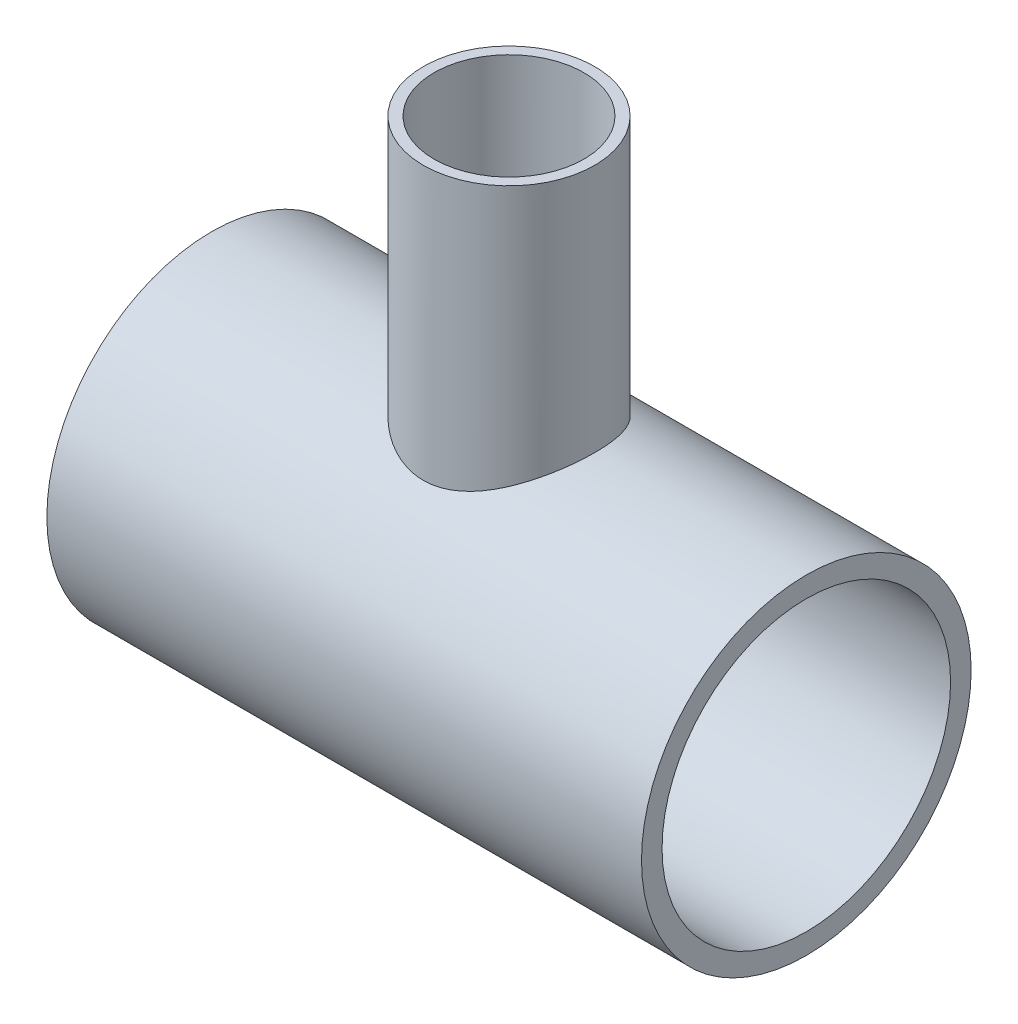
from build123d import *

# Parameters (mm, degrees)
REVOLVE_OF_12_NOM_W           = 584.2
REVOLVE_OF_12_NOM_H           = 20.193
F_6_NOM_OD_EXTRUDE_REACH      = 661.193
F_6_NOM_OD_EXTRUDE_END_RADIUS = 161.925
SKETCH2_R                     = 84.1375
F_6_NOM_ID_EXTRUDE_CUT_REACH  = 661.193
F_6_NOM_ID_EXTRUDE_R          = 73.6473


with BuildPart() as part:
    # Revolve of 12 NOM → Revolve12 NOM (revolve)
    with BuildSketch(Plane.XY):
        with Locations((0, 151.8285)):
            Rectangle(REVOLVE_OF_12_NOM_W, REVOLVE_OF_12_NOM_H)
    revolve(axis=Axis((0, 0, 0), (1, 0, 0)))

    # 6 NOM OD Extrude: up to this cylinder (the profile starts outside it)
    f_6_nom_od_extrude_end = Plane(origin=(0, 0, 0), z_dir=(-1, 0, 0)) * Cylinder(F_6_NOM_OD_EXTRUDE_END_RADIUS, 1647.236, mode=Mode.PRIVATE)
    # Sketch2 → 6 NOM OD Extrude (add, up to the surface)
    with BuildSketch(Plane(origin=(0, 406.4, 0), x_dir=(1, 0, 0), z_dir=(0, 1, 0)), mode=Mode.PRIVATE) as f_6_nom_od_extrude_sk1:
        Circle(SKETCH2_R)
    f_6_nom_od_extrude_tool1 = extrude(f_6_nom_od_extrude_sk1.sketch, amount=-F_6_NOM_OD_EXTRUDE_REACH, mode=Mode.PRIVATE) - f_6_nom_od_extrude_end
    add(f_6_nom_od_extrude_tool1.solids().sort_by_distance((0, 406.4, 0))[0])

    # 6 NOM ID Extrude → 6 NOM ID Extrude Cut (cut, up to next)
    with BuildSketch(Plane(origin=(0, 406.4, 0), x_dir=(1, 0, 0), z_dir=(0, 1, 0)), mode=Mode.PRIVATE) as f_6_nom_id_extrude_cut_sk1:
        Circle(F_6_NOM_ID_EXTRUDE_R)
    f_6_nom_id_extrude_cut_tool1 = extrude(f_6_nom_id_extrude_cut_sk1.sketch, amount=-F_6_NOM_ID_EXTRUDE_CUT_REACH, mode=Mode.PRIVATE) & part.part
    add(f_6_nom_id_extrude_cut_tool1.solids().sort_by_distance((0, 406.4, 0))[0], mode=Mode.SUBTRACT)


solid = part.part
